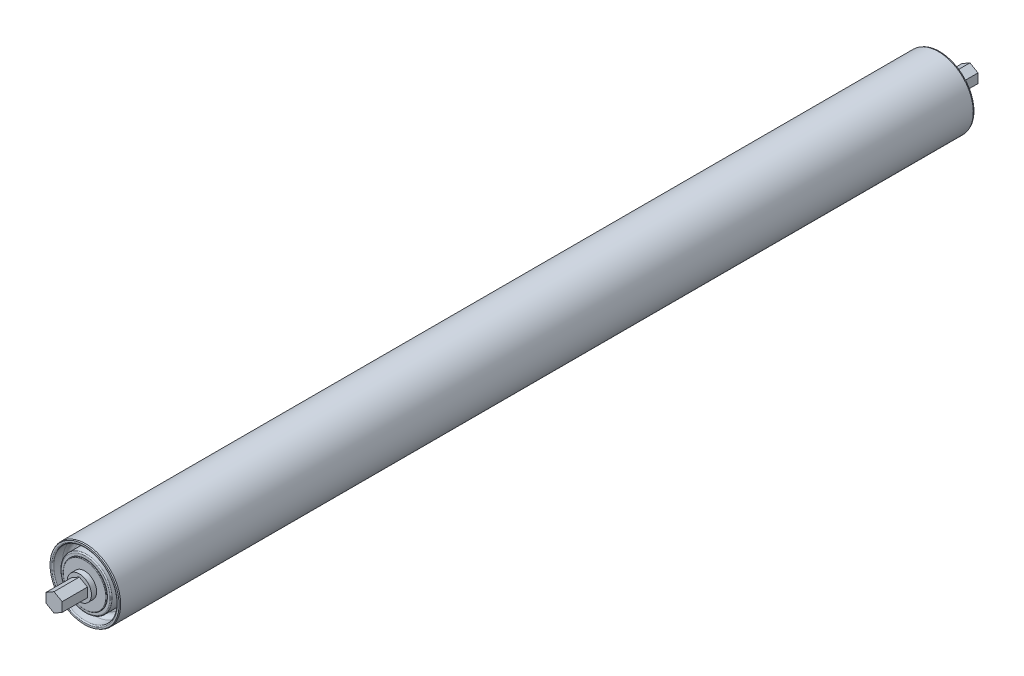
from build123d import *

# Parameters (mm, degrees)
BOSS_EXTRUDE1_DEPTH = 631.825


with BuildPart() as part:
    # Sketch3 → Revolve1 (revolve)
    with BuildSketch(Plane(origin=(0, 0, 0), x_dir=(0, 0, -1), z_dir=(1, 0, 0))):
        Polygon((315.9125, 5.55625), (298.45, 5.55625), (298.45, 8.334375), (294.878125, 8.334375), (294.878125, 23.8125), (294.084375, 24.13), (-294.084375, 24.13), (-294.878125, 23.8125), (-294.878125, 8.334375), (-298.45, 8.334375), (-298.45, 5.55625), (-315.9125, 5.55625), (-315.9125, 0), (315.9125, 0), align=None)
    revolve(axis=Axis((0, 0, 315.9125), (0, 0, -1)))

    # Sketch4 → Boss-Extrude1 (add)
    with BuildSketch(Plane.XY.offset(315.9125)):
        Polygon((0, 6.415804866), (-5.55625, 3.207902433), (-5.55625, -3.207902433), (0, -6.415804866), (5.55625, -3.207902433), (5.55625, 3.207902433), align=None)
    extrude(amount=-BOSS_EXTRUDE1_DEPTH)

    # Sketch6 → Cut-Revolve1 (revolve, cut)
    with BuildSketch(Plane(origin=(0, 0, 0), x_dir=(0, 0, -1), z_dir=(1, 0, 0))):
        with BuildLine():
            Line((-288.00425, 21.971), (-294.116125, 21.971))
            ThreePointArc((-294.116125, 21.971), (-294.654940367, 22.194184633), (-294.878125, 22.733))
            Line((-294.878125, 22.733), (-294.878125, 14.620875))
            ThreePointArc((-294.878125, 14.620875), (-294.766532684, 14.890282684), (-294.497125, 15.001875))
            Line((-294.497125, 15.001875), (-294.116125, 15.001875))
            Line((-294.116125, 15.001875), (-294.116125, 16.7401875))
            ThreePointArc((-294.116125, 16.7401875), (-293.892940367, 17.279002867), (-293.354125, 17.5021875))
            Line((-293.354125, 17.5021875), (-284.95625, 17.5021875))
            Line((-284.95625, 17.5021875), (-284.95625, 18.923))
            ThreePointArc((-284.95625, 18.923), (-285.848988531, 21.078261469), (-288.00425, 21.971))
        make_face()
    cut_revolve1 = revolve(axis=Axis((0, 0, 315.9125), (0, 0, -1)), mode=Mode.SUBTRACT)

    # Mirror2: Cut-Revolve1 across plane
    add(cut_revolve1.mirror(Plane.XY), mode=Mode.SUBTRACT)


solid = part.part
